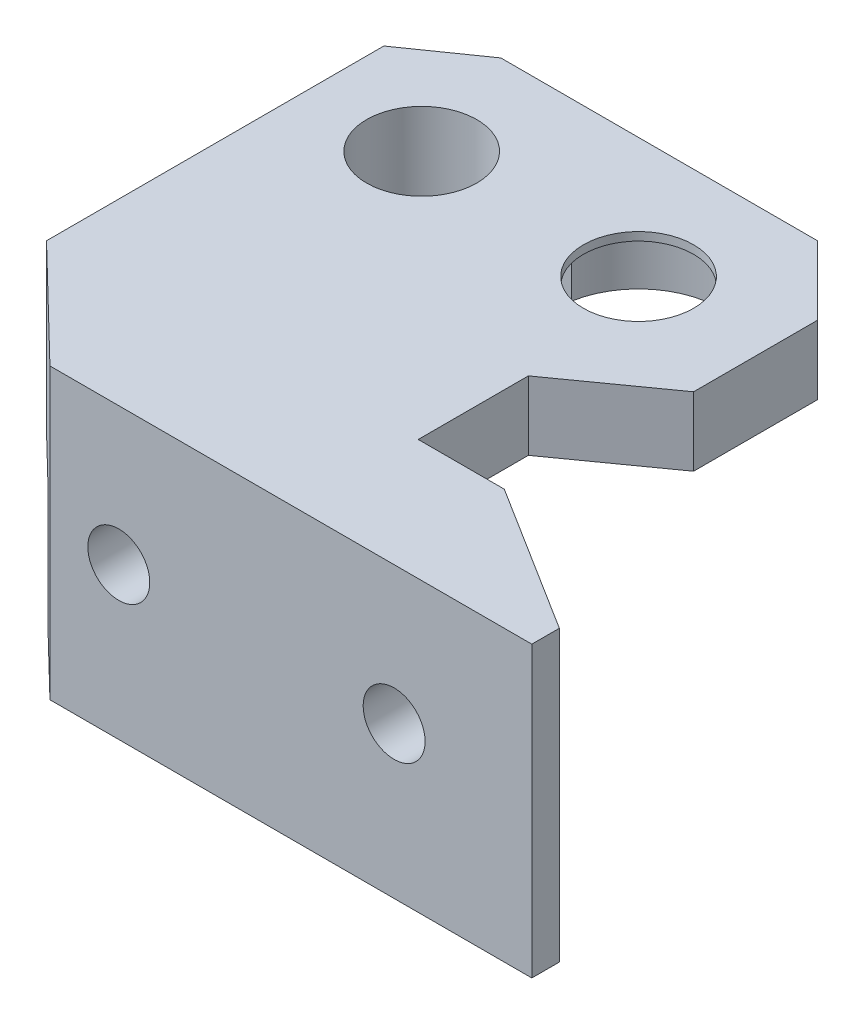
from build123d import *

# Parameters (mm, degrees)
SKETCH1_R           = 4
BOSS_EXTRUDE1_DEPTH = 5
BOSS_EXTRUDE2_DEPTH = 7
BOSS_EXTRUDE3_DEPTH = 16
SKETCH6_R           = 7
SKETCH6_R_2         = 4
BOSS_EXTRUDE4_DEPTH = 2.5
CUT_EXTRUDE1_DEPTH  = 4.4
CUT_EXTRUDE2_DEPTH  = 21.4
SKETCH8_R           = 2.25
CUT_EXTRUDE3_DEPTH  = 36.75
SKETCH9_R           = 4
CUT_EXTRUDE4_DEPTH  = 4
SKETCH10_W          = 49.722079373
SKETCH10_H          = 35.75
CUT_EXTRUDE5_DEPTH  = 22


with BuildPart() as part:
    # Sketch1 → Boss-Extrude1 (new body)
    with BuildSketch(Plane(origin=(0, 0, 0), x_dir=(1, 0, 0), z_dir=(0, 1, 0))):
        Polygon((-4.25, 8.75), (18.75, 8.75), (23.75, 5.25), (23.75, -19.25), (15.75, -27), (-19.25, -27), (-19.25, -25), (-8.5, -18.25), (-2.25, -18.25), (-2.25, -10.25), (-9.25, -5.25), (-9.25, 3.75), align=None)
        Circle(SKETCH1_R, mode=Mode.SUBTRACT)
        with Locations((15.75, 0)):
            Circle(SKETCH1_R, mode=Mode.SUBTRACT)
    boss_extrude1 = extrude(amount=BOSS_EXTRUDE1_DEPTH)

    # Sketch2 → Boss-Extrude2 (add)
    with BuildSketch(Plane.XZ):
        Polygon((23.75, 19.25), (23.75, -5.25), (20.25, -5.25), (20.25, 18.25), (-8.5, 18.25), (-14.87037037, 22.25), (20.653225806, 22.25), align=None)
    boss_extrude2 = extrude(amount=BOSS_EXTRUDE2_DEPTH)

    # Sketch3 → Boss-Extrude3 (add)
    with BuildSketch(Plane.XZ):
        Polygon((-14.87037037, 22.25), (20.653225806, 22.25), (15.75, 27), (-19.25, 27), (-19.25, 25), align=None)
    boss_extrude3 = extrude(amount=BOSS_EXTRUDE3_DEPTH)

    # Sketch6 → Boss-Extrude4 (add)
    with BuildSketch(Plane.XZ):
        with Locations((15.75, 0)):
            Circle(SKETCH6_R)
        with Locations((15.75, 0)):
            Circle(SKETCH6_R_2, mode=Mode.SUBTRACT)
    boss_extrude4 = extrude(amount=BOSS_EXTRUDE4_DEPTH)

    # Sketch4 → Cut-Extrude1 (cut)
    with BuildSketch(Plane.XZ):
        with BuildLine():
            Line((5.883782294, -1), (12.395898034, -1))
            ThreePointArc((12.395898034, -1), (12.25, 0), (12.395898034, 1))
            Line((12.395898034, 1), (5.883782294, 1))
            ThreePointArc((5.883782294, 1), (-5.968156673, 0), (5.883782294, -1))
        make_face()
    cut_extrude1 = extrude(amount=-CUT_EXTRUDE1_DEPTH, mode=Mode.SUBTRACT)

    # Sketch7 → Cut-Extrude2 (cut, through all)
    with BuildSketch(Plane.XZ.offset(-4.4)):
        with BuildLine():
            Line((5.883782294, -1), (11.877016654, -1))
            ThreePointArc((11.877016654, -1), (11.75, 0), (11.877016654, 1))
            Line((11.877016654, 1), (5.883782294, 1))
            ThreePointArc((5.883782294, 1), (-5.968156673, 0), (5.883782294, -1))
        make_face()
    cut_extrude2 = extrude(amount=CUT_EXTRUDE2_DEPTH, mode=Mode.SUBTRACT)

    # Sketch8 → Cut-Extrude3 (cut, through all)
    with BuildSketch(Plane.XY.offset(27)):
        with Locations((10.75, -5)):
            Circle(SKETCH8_R)
        with Locations((-9.25, -5)):
            Circle(SKETCH8_R)
    cut_extrude3 = extrude(amount=-CUT_EXTRUDE3_DEPTH, mode=Mode.SUBTRACT)

    # Sketch9 → Cut-Extrude4 (cut)
    with BuildSketch(Plane(origin=(0, 0, 18.25), x_dir=(-1, 0, 0), z_dir=(0, 0, -1))):
        with Locations((-10.75, -5)):
            Circle(SKETCH9_R)
        with Locations((9.25, -5)):
            Circle(SKETCH9_R)
    cut_extrude4 = extrude(amount=-CUT_EXTRUDE4_DEPTH, mode=Mode.SUBTRACT)

    # Mirror1: Boss-Extrude1, Boss-Extrude2, Boss-Extrude3, Boss-Extrude4, Cut-Extrude1, Cut-Extrude2, Cut-Extrude3, Cut-Extrude4 across plane
    add(boss_extrude1.mirror(Plane(origin=(-19.25, 5, 27), x_dir=(0, 0, 1), z_dir=(1, 0, 0))))
    add(boss_extrude2.mirror(Plane(origin=(-19.25, 5, 27), x_dir=(0, 0, 1), z_dir=(1, 0, 0))))
    add(boss_extrude3.mirror(Plane(origin=(-19.25, 5, 27), x_dir=(0, 0, 1), z_dir=(1, 0, 0))))
    add(boss_extrude4.mirror(Plane(origin=(-19.25, 5, 27), x_dir=(0, 0, 1), z_dir=(1, 0, 0))))
    add(cut_extrude1.mirror(Plane(origin=(-19.25, 5, 27), x_dir=(0, 0, 1), z_dir=(1, 0, 0))), mode=Mode.SUBTRACT)
    add(cut_extrude2.mirror(Plane(origin=(-19.25, 5, 27), x_dir=(0, 0, 1), z_dir=(1, 0, 0))), mode=Mode.SUBTRACT)
    add(cut_extrude3.mirror(Plane(origin=(-19.25, 5, 27), x_dir=(0, 0, 1), z_dir=(1, 0, 0))), mode=Mode.SUBTRACT)
    add(cut_extrude4.mirror(Plane(origin=(-19.25, 5, 27), x_dir=(0, 0, 1), z_dir=(1, 0, 0))), mode=Mode.SUBTRACT)

    # Sketch10 → Cut-Extrude5 (cut, through all)
    with BuildSketch(Plane(origin=(0, 5, 0), x_dir=(1, 0, 0), z_dir=(0, 1, 0))):
        with Locations((5.611039687, -9.125)):
            Rectangle(SKETCH10_W, SKETCH10_H)
    extrude(amount=-CUT_EXTRUDE5_DEPTH, mode=Mode.SUBTRACT)


solid = part.part
